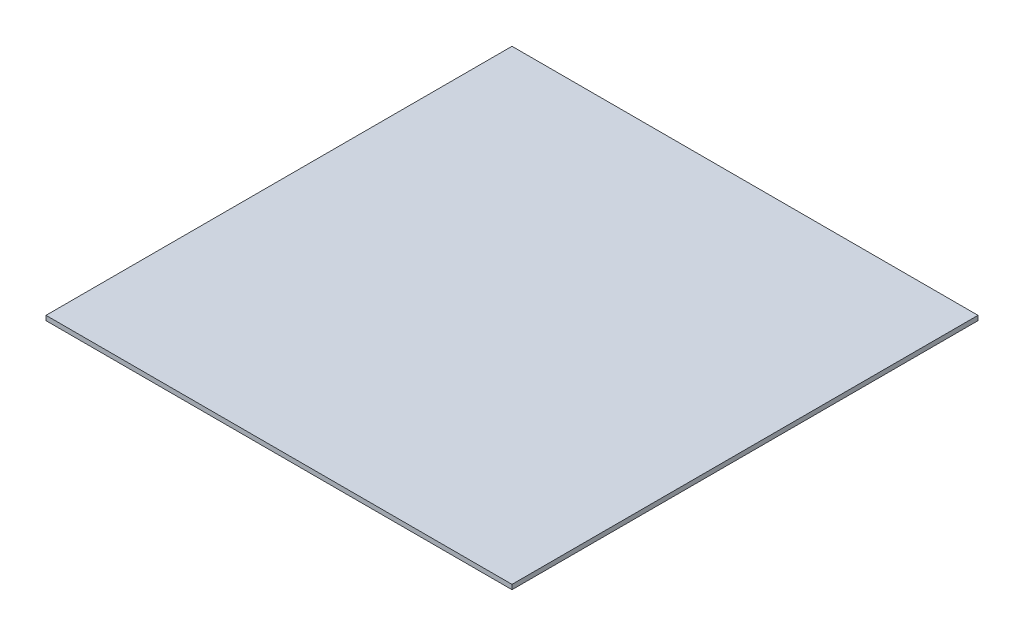
from build123d import *

# Parameters (mm, degrees)
SKETCH1_W           = 100
SKETCH1_H           = 100
BOSS_EXTRUDE1_DEPTH = 1


with BuildPart() as part:
    # Sketch1 → Boss-Extrude1 (new body)
    with BuildSketch(Plane(origin=(0, 0, 0), x_dir=(1, 0, 0), z_dir=(0, 1, 0))):
        Rectangle(SKETCH1_W, SKETCH1_H)
    extrude(amount=BOSS_EXTRUDE1_DEPTH)


solid = part.part
